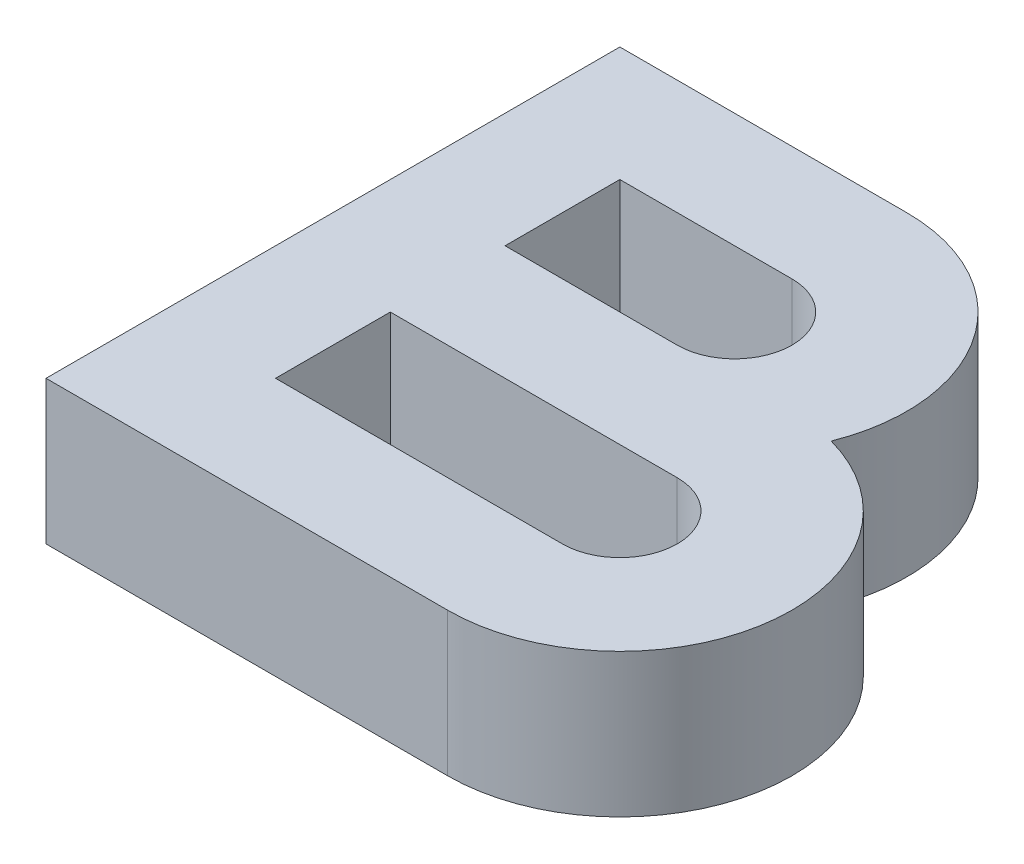
from build123d import *

# Parameters (mm, degrees)
BOSS_EXTRUDE1_DEPTH = 10


with BuildPart() as part:
    # Sketch1 → Boss-Extrude1 (new body)
    with BuildSketch(Plane(origin=(0, 0, 0), x_dir=(1, 0, 0), z_dir=(0, 1, 0))):
        with BuildLine():
            Line((50, 0), (50, 40))
            Line((50, 40), (70, 40))
            ThreePointArc((70, 40), (79.926416645, 34.742866793), (81.155417528, 23.577708764))
            ThreePointArc((81.155417528, 23.577708764), (89.893958659, 10.408225074), (78, 0))
            Line((78, 0), (50, 0))
        make_face()
        with BuildLine():
            Line((58, 32), (58, 24))
            Line((58, 24), (70, 24))
            ThreePointArc((70, 24), (74, 28), (70, 32))
            Line((70, 32), (58, 32))
        make_face(mode=Mode.SUBTRACT)
        with BuildLine():
            Line((58, 8), (78, 8))
            ThreePointArc((78, 8), (82, 12), (78, 16))
            Line((78, 16), (58, 16))
            Line((58, 16), (58, 8))
        make_face(mode=Mode.SUBTRACT)
    extrude(amount=BOSS_EXTRUDE1_DEPTH)


solid = part.part
